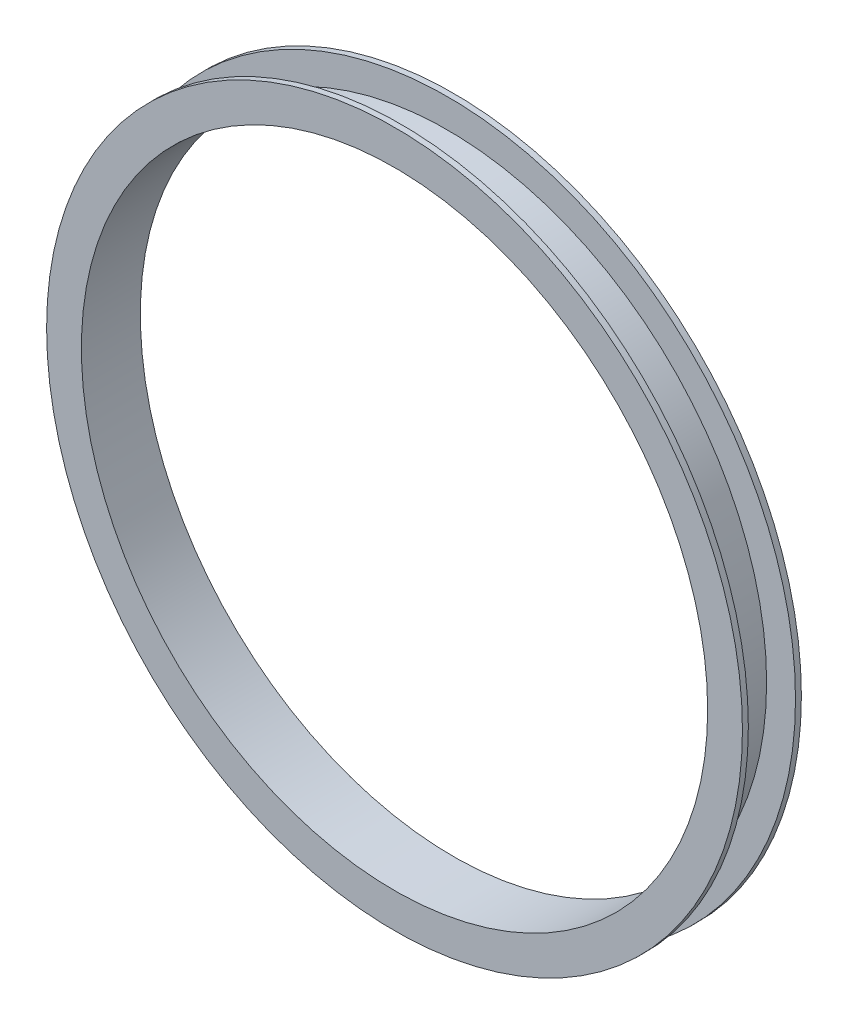
from build123d import *

# Parameters (mm, degrees)
SKETCH2_R           = 187.3885
SKETCH2_R_2         = 168.656
BOSS_EXTRUDE1_DEPTH = 3.175
SKETCH3_R           = 171.831
SKETCH3_R_2         = 168.656
BOSS_EXTRUDE2_DEPTH = 25.4
SKETCH4_R           = 187.3885
SKETCH4_R_2         = 168.656
BOSS_EXTRUDE3_DEPTH = 3.175


with BuildPart() as part:
    # Sketch2 → Boss-Extrude1 (new body)
    with BuildSketch(Plane.XY):
        Circle(SKETCH2_R)
        Circle(SKETCH2_R_2, mode=Mode.SUBTRACT)
    extrude(amount=BOSS_EXTRUDE1_DEPTH)

    # Sketch3 → Boss-Extrude2 (add)
    with BuildSketch(Plane.XY.offset(3.175)):
        Circle(SKETCH3_R)
        Circle(SKETCH3_R_2, mode=Mode.SUBTRACT)
    extrude(amount=BOSS_EXTRUDE2_DEPTH)

    # Sketch4 → Boss-Extrude3 (add)
    with BuildSketch(Plane.XY.offset(28.575)):
        Circle(SKETCH4_R)
        Circle(SKETCH4_R_2, mode=Mode.SUBTRACT)
    extrude(amount=BOSS_EXTRUDE3_DEPTH)


solid = part.part
